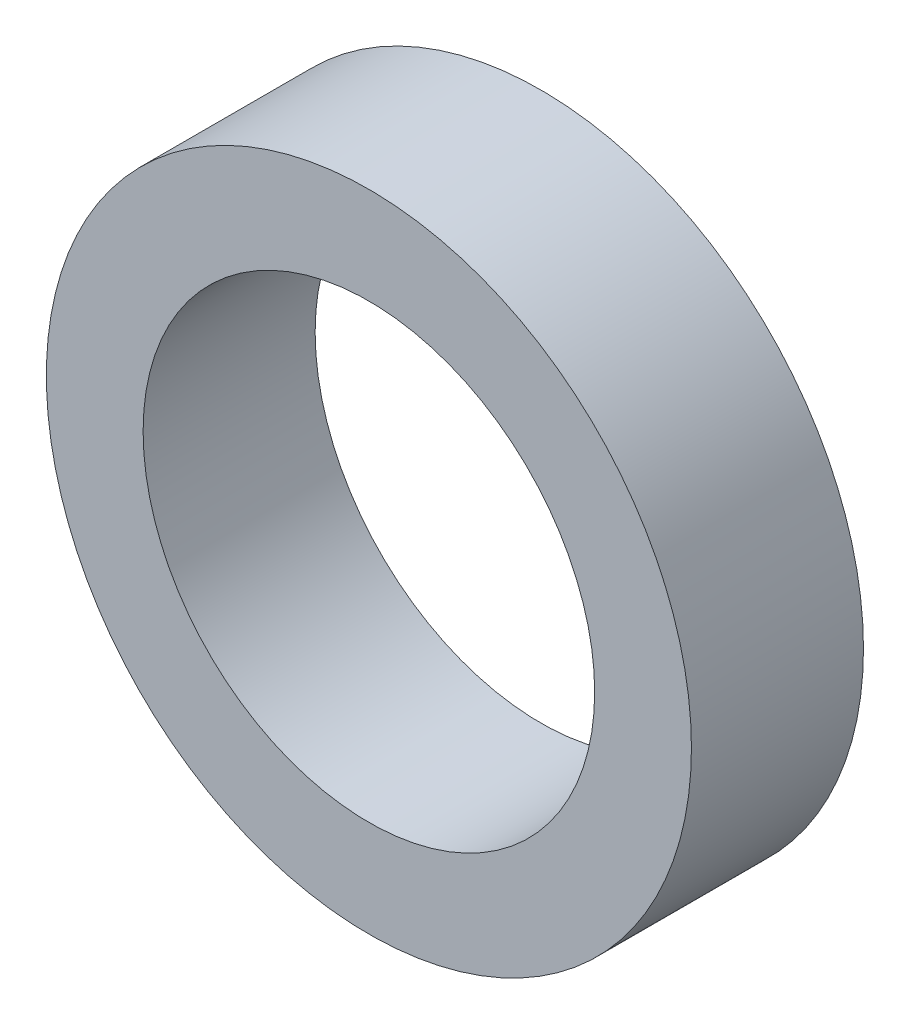
from build123d import *

# Parameters (mm, degrees)
SKETCH_1_R      = 3
SKETCH_1_R_2    = 2.1
EXTRUDE_1_DEPTH = 1.6


with BuildPart() as part:
    # 草图1 → 凸台-拉伸1 (new body)
    with BuildSketch(Plane.XY):
        Circle(SKETCH_1_R)
        Circle(SKETCH_1_R_2, mode=Mode.SUBTRACT)
    extrude(amount=EXTRUDE_1_DEPTH)


solid = part.part
